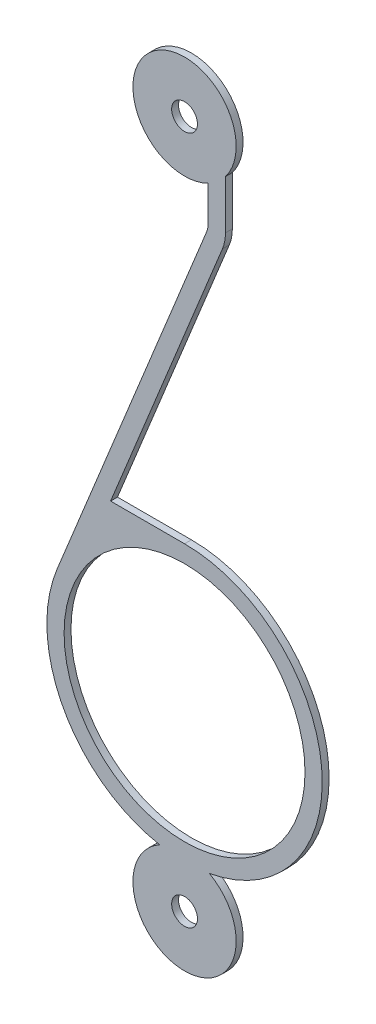
from build123d import *

# Parameters (mm, degrees)
SKETCH1_R           = 0.375
SKETCH1_R_2         = 3.5
BOSS_EXTRUDE1_DEPTH = 0.1


with BuildPart() as part:
    # Sketch1 → Boss-Extrude1 (new body, symmetric)
    with BuildSketch(Plane.XY):
        with BuildLine():
            Line((0.636628274, 7.407290054), (-3.704019046, -3.239952681))
            ThreePointArc((-3.704019046, -3.239952681), (-3.507926477, -6.672095687), (-0.720779018, -8.68452381))
            ThreePointArc((-0.720779018, -8.68452381), (0, -11.5), (0.720779018, -8.68452381))
            ThreePointArc((0.720779018, -8.68452381), (3.983597321, -4.388126568), (0, -0.75))
            Line((0, -0.75), (-2.148965927, -0.75))
            Line((-2.148965927, -0.75), (1.099630654, 7.218534139))
            ThreePointArc((1.099630654, 7.218534139), (1.165325631, 7.4384166), (1.1875, 7.666829437))
            Line((1.1875, 7.666829437), (1.1875, 9.083570106))
            ThreePointArc((1.1875, 9.083570106), (-0.960377242, 11.152248043), (0.6875, 8.666829437))
            Line((0.6875, 8.666829437), (0.6875, 7.666829437))
            ThreePointArc((0.6875, 7.666829437), (0.674662207, 7.534590426), (0.636628274, 7.407290054))
        make_face()
        with Locations((0, 10)):
            Circle(SKETCH1_R, mode=Mode.SUBTRACT)
        with Locations((0, -10)):
            Circle(SKETCH1_R, mode=Mode.SUBTRACT)
        with Locations((0, -4.75)):
            Circle(SKETCH1_R_2, mode=Mode.SUBTRACT)
    extrude(amount=BOSS_EXTRUDE1_DEPTH, both=True)


solid = part.part
